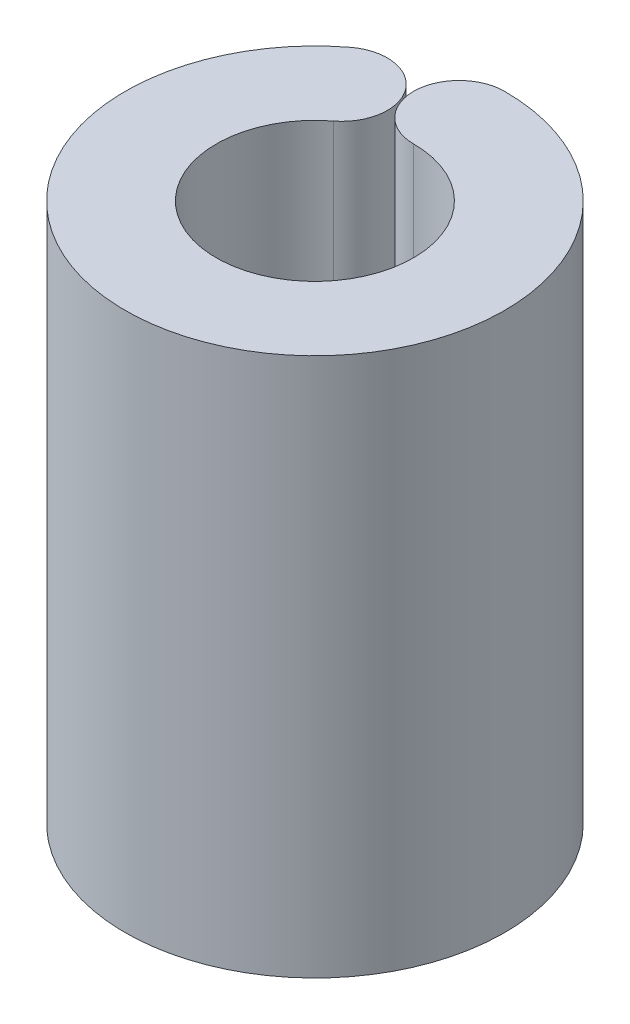
from build123d import *

# Parameters (mm, degrees)
BOSS_EXTRUDE1_DEPTH = 14.2


with BuildPart() as part:
    # Sketch1 → Boss-Extrude1 (new body)
    with BuildSketch(Plane(origin=(0, 0, 0), x_dir=(1, 0, 0), z_dir=(0, 1, 0))):
        with BuildLine():
            ThreePointArc((0, 2.6), (0.833935879, -2.4626309), (-1.579750972, 2.065039192))
            ThreePointArc((-1.579750972, 2.065039192), (-1.355771794, 3.747250038), (-3.037982639, 3.971229216))
            ThreePointArc((-3.037982639, 3.971229216), (1.603722844, -4.735828654), (0, 5))
            ThreePointArc((0, 5), (-1.2, 3.8), (0, 2.6))
        make_face()
    extrude(amount=BOSS_EXTRUDE1_DEPTH)


solid = part.part
